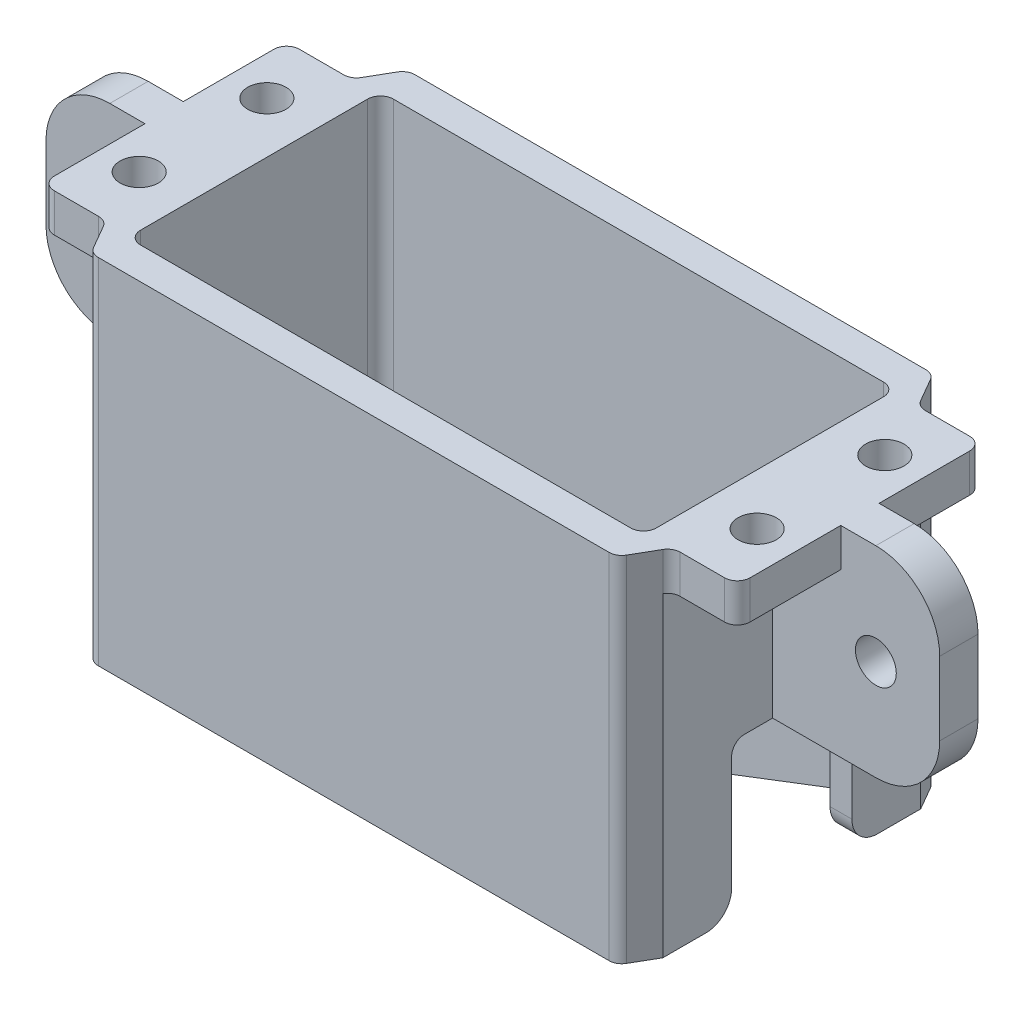
from build123d import *

# Parameters (mm, degrees)
SCHIZZO3_R                   = 1.5
ESTRUSIONE_ESTRUSIONE2_DEPTH = 27.7
TAGLIO_ESTRUSIONE1_REACH     = 56.5
TAGLIO_ESTRUSIONE2_START     = -3
TAGLIO_ESTRUSIONE2_DEPTH     = 24.7
RACCORDO1_R                  = 2
SCHIZZO6_R                   = 1.6
ESTRUSIONE_ESTRUSIONE3_DEPTH = 1.5
SCHIZZO8_R                   = 1.6
ESTRUSIONE_ESTRUSIONE4_DEPTH = 2.5
RACCORDO2_R                  = 2


with BuildPart() as part:
    # Schizzo3 → Estrusione-Estrusione2 (new body)
    with BuildSketch(Plane(origin=(0, -1.8, 0), x_dir=(1, 0, 0), z_dir=(0, 1, 0))):
        with BuildLine():
            Line((27.25, -1.6), (27.25, -8.6))
            ThreePointArc((27.25, -8.6), (26.957106781, -9.307106781), (26.25, -9.6))
            Line((26.25, -9.6), (22.777350269, -9.6))
            ThreePointArc((22.777350269, -9.6), (22.277350269, -9.733974596), (21.911324865, -10.1))
            Line((21.911324865, -10.1), (20.872094381, -11.9))
            ThreePointArc((20.872094381, -11.9), (20.506068977, -12.266025404), (20.006068977, -12.4))
            Line((20.006068977, -12.4), (-20.006068977, -12.4))
            ThreePointArc((-20.006068977, -12.4), (-20.506068977, -12.266025404), (-20.872094381, -11.9))
            Line((-20.872094381, -11.9), (-21.911324865, -10.1))
            ThreePointArc((-21.911324865, -10.1), (-22.277350269, -9.733974596), (-22.777350269, -9.6))
            Line((-22.777350269, -9.6), (-26.25, -9.6))
            ThreePointArc((-26.25, -9.6), (-26.957106781, -9.307106781), (-27.25, -8.6))
            Line((-27.25, -8.6), (-27.25, -1.6))
            Line((-27.25, -1.6), (-27.25, 1.6))
            Line((-27.25, 1.6), (-27.25, 8.6))
            ThreePointArc((-27.25, 8.6), (-26.957106781, 9.307106781), (-26.25, 9.6))
            Line((-26.25, 9.6), (-22.777350269, 9.6))
            ThreePointArc((-22.777350269, 9.6), (-22.277350269, 9.733974596), (-21.911324865, 10.1))
            Line((-21.911324865, 10.1), (-20.872094381, 11.9))
            ThreePointArc((-20.872094381, 11.9), (-20.506068977, 12.266025404), (-20.006068977, 12.4))
            Line((-20.006068977, 12.4), (20.006068977, 12.4))
            ThreePointArc((20.006068977, 12.4), (20.506068977, 12.266025404), (20.872094381, 11.9))
            Line((20.872094381, 11.9), (21.911324865, 10.1))
            ThreePointArc((21.911324865, 10.1), (22.277350269, 9.733974596), (22.777350269, 9.6))
            Line((22.777350269, 9.6), (26.25, 9.6))
            ThreePointArc((26.25, 9.6), (26.957106781, 9.307106781), (27.25, 8.6))
            Line((27.25, 8.6), (27.25, 1.6))
            Line((27.25, 1.6), (27.25, -1.6))
        make_face()
        with Locations((24.2, -5)):
            Circle(SCHIZZO3_R, mode=Mode.SUBTRACT)
        with Locations((24.2, 5)):
            Circle(SCHIZZO3_R, mode=Mode.SUBTRACT)
        with Locations((-24.2, 5)):
            Circle(SCHIZZO3_R, mode=Mode.SUBTRACT)
        with Locations((-24.2, -5)):
            Circle(SCHIZZO3_R, mode=Mode.SUBTRACT)
        with BuildLine():
            Line((-19.2, -9.9), (19.2, -9.9))
            ThreePointArc((19.2, -9.9), (19.907106781, -9.607106781), (20.2, -8.9))
            Line((20.2, -8.9), (20.2, 8.9))
            ThreePointArc((20.2, 8.9), (19.907106781, 9.607106781), (19.2, 9.9))
            Line((19.2, 9.9), (-19.2, 9.9))
            ThreePointArc((-19.2, 9.9), (-19.907106781, 9.607106781), (-20.2, 8.9))
            Line((-20.2, 8.9), (-20.2, -8.9))
            ThreePointArc((-20.2, -8.9), (-19.907106781, -9.607106781), (-19.2, -9.9))
        make_face(mode=Mode.SUBTRACT)
    extrude(amount=-ESTRUSIONE_ESTRUSIONE2_DEPTH)

    # Schizzo4 → Taglio-Estrusione1 (cut, up to next)
    with BuildSketch(Plane(origin=(27.25, 0, 0), x_dir=(0, 0, -1), z_dir=(1, 0, 0)), mode=Mode.PRIVATE) as taglio_estrusione1_sk1:
        with BuildLine():
            Line((-3.710237866, -17.5387571), (3.710237866, -17.5387571))
            ThreePointArc((3.710237866, -17.5387571), (4.417344647, -17.831650319), (4.710237866, -18.5387571))
            Line((4.710237866, -18.5387571), (4.710237866, -30.61702325))
            ThreePointArc((4.710237866, -30.61702325), (4.417344647, -31.324130031), (3.710237866, -31.61702325))
            Line((3.710237866, -31.61702325), (-3.710237866, -31.61702325))
            ThreePointArc((-3.710237866, -31.61702325), (-4.417344647, -31.324130031), (-4.710237866, -30.61702325))
            Line((-4.710237866, -30.61702325), (-4.710237866, -18.5387571))
            ThreePointArc((-4.710237866, -18.5387571), (-4.417344647, -17.831650319), (-3.710237866, -17.5387571))
        make_face()
    taglio_estrusione1_tool1 = extrude(taglio_estrusione1_sk1.sketch, amount=-TAGLIO_ESTRUSIONE1_REACH, mode=Mode.PRIVATE) & part.part
    add(taglio_estrusione1_tool1.solids().sort_by_distance((27.25, -24.57789, 0))[0], mode=Mode.SUBTRACT)

    # Schizzo5 → Taglio-Estrusione2 (cut)
    with BuildSketch(Plane(origin=(0, -1.8, 0), x_dir=(1, 0, 0), z_dir=(0, 1, 0)).offset(TAGLIO_ESTRUSIONE2_START)):
        Polygon((27.25, 8.6), (27.25, -8.6), (27.507432363, -11.370727038), (21.911324865, -11.370727038), (21.911324865, -9.6), (21.911324865, 9.6), (21.911324865, 11.665734377), (27.25, 11.503675338), align=None)
    taglio_estrusione2 = extrude(amount=-TAGLIO_ESTRUSIONE2_DEPTH, mode=Mode.SUBTRACT)

    # Specchia1: Taglio-Estrusione2 across plane
    add(taglio_estrusione2.mirror(Plane(origin=(0, 0, 0), x_dir=(0, 0, 1), z_dir=(1, 0, 0))), mode=Mode.SUBTRACT)

    # Raccordo1
    raccordo1_edges = [part.edges().sort_by_distance(p)[0] for p in [
        (21.055662433, -29.5, -4.710237866),
        (21.055662433, -29.5, 4.710237866),
    ]]
    fillet(raccordo1_edges, radius=RACCORDO1_R)

    # Schizzo6 → Estrusione-Estrusione3 (add, symmetric)
    with BuildSketch(Plane.XY):
        with BuildLine():
            Line((21.911324865, -17.5387571), (30, -17.5387571))
            ThreePointArc((30, -17.5387571), (33.535533906, -16.074291006), (35, -12.5387571))
            Line((35, -12.5387571), (35, -6.8))
            ThreePointArc((35, -6.8), (33.535533906, -3.264466094), (30, -1.8))
            Line((30, -1.8), (21.911324865, -1.8))
            Line((21.911324865, -1.8), (21.911324865, -17.5387571))
        make_face()
        with Locations((30, -9.66937855)):
            Circle(SCHIZZO6_R, mode=Mode.SUBTRACT)
    estrusione_estrusione3 = extrude(amount=ESTRUSIONE_ESTRUSIONE3_DEPTH, both=True)

    # Schizzo8 → Estrusione-Estrusione4 (add)
    with BuildSketch(Plane(origin=(0, 0, -12.4), x_dir=(-1, 0, 0), z_dir=(0, 0, -1))):
        with BuildLine():
            Line((-20.006068977, -29.5), (-1.786501868, -36.469947652))
            ThreePointArc((-1.786501868, -36.469947652), (0, -36.8), (1.786501868, -36.469947652))
            Line((1.786501868, -36.469947652), (20.006068977, -29.5))
            Line((20.006068977, -29.5), (-20.006068977, -29.5))
        make_face()
        with Locations((0, -31.8)):
            Circle(SCHIZZO8_R, mode=Mode.SUBTRACT)
    extrude(amount=-ESTRUSIONE_ESTRUSIONE4_DEPTH)

    # Specchia2: Estrusione-Estrusione3 across plane
    add(estrusione_estrusione3.mirror(Plane(origin=(0, 0, 0), x_dir=(0, 0, 1), z_dir=(1, 0, 0))))

    # Raccordo2
    raccordo2_edges = [part.edges().sort_by_distance(p)[0] for p in [
        (-21.911324865, -17.5387571, 0),
    ]]
    fillet(raccordo2_edges, radius=RACCORDO2_R)


solid = part.part
